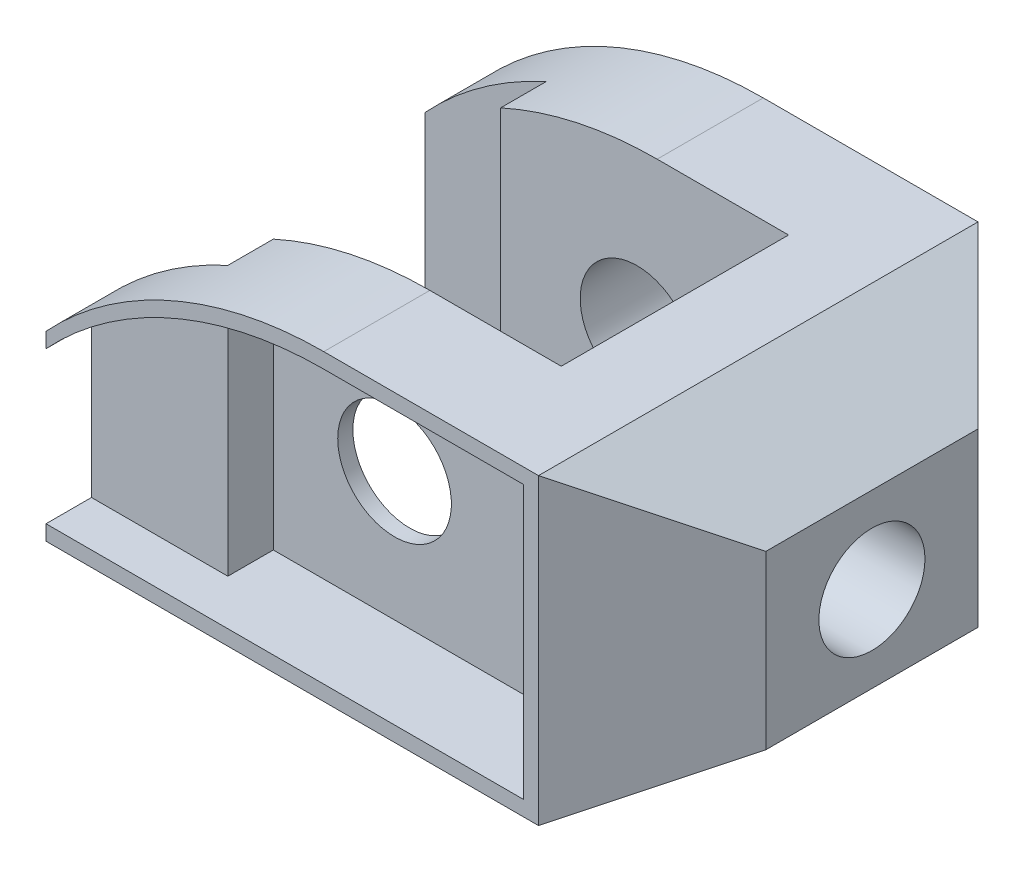
from build123d import *

# Parameters (mm, degrees)
SKETCH1_R                = 7.5
BOSS_EXTRUDE1_DEPTH      = 58
SKETCH5_R                = 7
CUT_EXTRUDE1_DEPTH       = 81
CUT_EXTRUDE3_DEPTH       = 22.0000001
CUT_EXTRUDE3_DEPTH_BACK  = 20
SKETCH7_W                = 16
SKETCH7_H                = 6
CUT_EXTRUDE5_DEPTH       = 22
CUT_EXTRUDE5_DEPTH_BACK  = 20
CUT_EXTRUDE14_DEPTH      = 24
CUT_EXTRUDE14_DEPTH_BACK = 24
SKETCH15_R               = 7.5
CUT_EXTRUDE16_DEPTH      = 1
CUT_EXTRUDE16_DEPTH_BACK = 6
CUT_EXTRUDE19_DEPTH      = 6


with BuildPart() as part:
    # Sketch1 → Boss-Extrude1 (new body)
    with BuildSketch(Plane.XY):
        with BuildLine():
            Line((-34, -19), (31, -19))
            Line((31, -19), (46, -10.339745962))
            Line((46, -10.339745962), (46, 12.339745962))
            Line((46, 12.339745962), (31, 21))
            Line((31, 21), (2.66060556, 21))
            ThreePointArc((2.66060556, 21), (-17.33939444, 16.82575695), (-34, 5))
            Line((-34, 5), (-34, -19))
        make_face()
        Circle(SKETCH1_R, mode=Mode.SUBTRACT)
    extrude(amount=BOSS_EXTRUDE1_DEPTH)

    # Sketch5 → Cut-Extrude1 (cut, through all)
    with BuildSketch(Plane(origin=(46, 0, 0), x_dir=(0, 0, -1), z_dir=(1, 0, 0))):
        with Locations((-29, 1)):
            Circle(SKETCH5_R)
    extrude(amount=-CUT_EXTRUDE1_DEPTH, mode=Mode.SUBTRACT)

    # Sketch6 → Cut-Extrude3 (cut, two sides)
    with BuildSketch(Plane(origin=(0, 0, 0), x_dir=(1, 0, 0), z_dir=(0, 1, 0))) as cut_extrude3_sk:
        Polygon((-226.60339564, -14), (-34, -14), (20, -14), (20, -44), (-34, -44), (-226.60339564, -44), (-611.81018692, -44), (-611.81018692, -14), align=None)
    extrude(amount=CUT_EXTRUDE3_DEPTH, mode=Mode.SUBTRACT)
    extrude(cut_extrude3_sk.sketch, amount=-CUT_EXTRUDE3_DEPTH_BACK, mode=Mode.SUBTRACT)

    # Sketch7 → Cut-Extrude5 (cut, two sides)
    with BuildSketch(Plane(origin=(0, 0, 0), x_dir=(1, 0, 0), z_dir=(0, 1, 0))) as cut_extrude5_sk:
        with Locations((-26, -11)):
            Rectangle(SKETCH7_W, SKETCH7_H)
        with Locations((-26, -47)):
            Rectangle(SKETCH7_W, SKETCH7_H)
    extrude(amount=CUT_EXTRUDE5_DEPTH, mode=Mode.SUBTRACT)
    extrude(cut_extrude5_sk.sketch, amount=-CUT_EXTRUDE5_DEPTH_BACK, mode=Mode.SUBTRACT)

    # Sketch14 → Cut-Extrude14 (cut, two sides)
    with BuildSketch(Plane(origin=(0, 0, 0), x_dir=(1, 0, 0), z_dir=(0, 1, 0))) as cut_extrude14_sk:
        Polygon((31, 0), (46, 0), (46, -15), align=None)
        Polygon((31, -58), (46, -58), (46, -43), align=None)
    extrude(amount=CUT_EXTRUDE14_DEPTH, mode=Mode.SUBTRACT)
    extrude(cut_extrude14_sk.sketch, amount=-CUT_EXTRUDE14_DEPTH_BACK, mode=Mode.SUBTRACT)

    # Sketch15 → Cut-Extrude16 (cut, two sides)
    with BuildSketch(Plane.XY.offset(58)) as cut_extrude16_sk:
        with BuildLine():
            Line((29, -17), (29, 19))
            Line((29, 19), (2.66060556, 19))
            ThreePointArc((2.66060556, 19), (-17.33939444, 14.82575695), (-34, 3))
            Line((-34, 3), (-34, -17))
            Line((-34, -17), (29, -17))
        make_face()
        Circle(SKETCH15_R, mode=Mode.SUBTRACT)
    extrude(amount=CUT_EXTRUDE16_DEPTH, mode=Mode.SUBTRACT)
    extrude(cut_extrude16_sk.sketch, amount=-CUT_EXTRUDE16_DEPTH_BACK, mode=Mode.SUBTRACT)

    # Sketch19 → Cut-Extrude19 (cut)
    with BuildSketch(Plane.XY.offset(52)):
        with BuildLine():
            Line((29, -17), (-16, -17))
            Line((-16, -17), (-16, 15.387302143))
            ThreePointArc((-16, 15.387302143), (-6.842943589, 18.088517533), (2.66060556, 19))
            Line((2.66060556, 19), (29, 19))
            Line((29, 19), (29, -17))
        make_face()
    extrude(amount=-CUT_EXTRUDE19_DEPTH, mode=Mode.SUBTRACT)


solid = part.part
